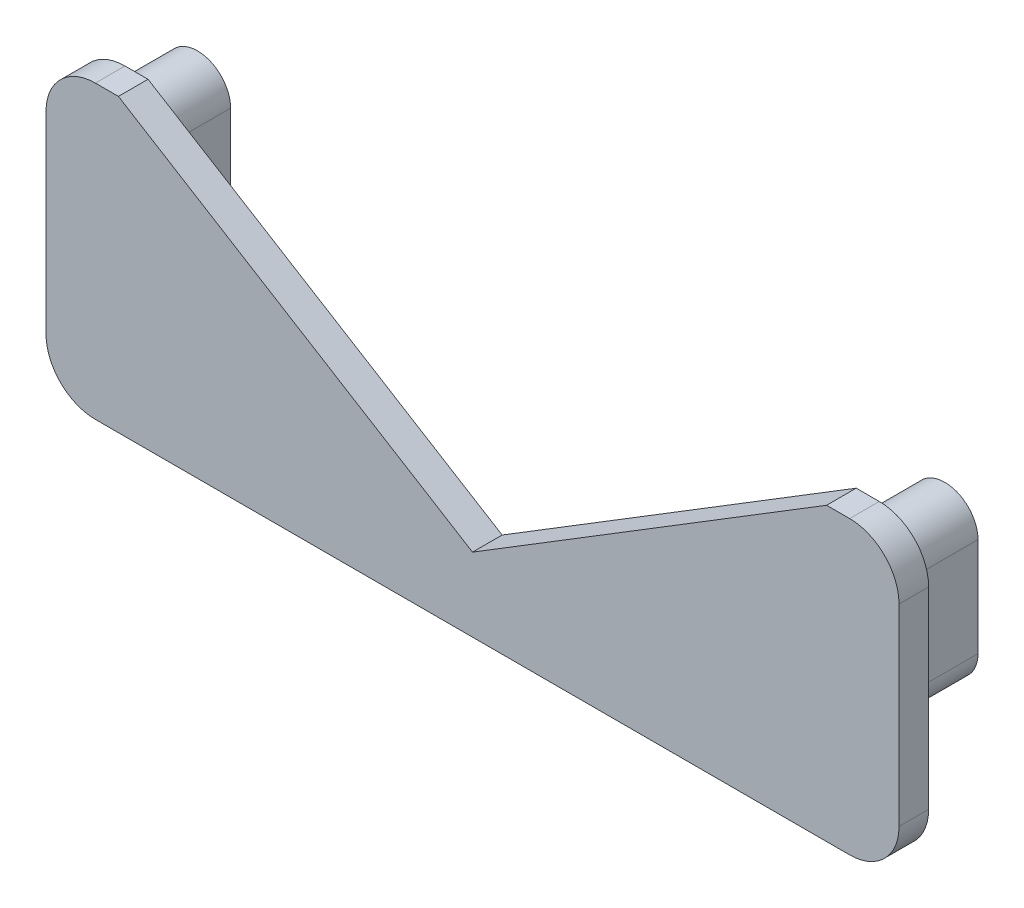
from build123d import *

# Parameters (mm, degrees)
BOSS_EXTRUDE1_DEPTH = 3
BOSS_EXTRUDE2_DEPTH = 7


with BuildPart() as part:
    # Sketch1 → Boss-Extrude1 (new body)
    with BuildSketch(Plane.XY):
        with BuildLine():
            ThreePointArc((-43.2, -9.751954051), (-41.735533906, -13.287487956), (-38.2, -14.751954051))
            Line((-38.2, -14.751954051), (38.2, -14.751954051))
            ThreePointArc((38.2, -14.751954051), (41.735533906, -13.287487956), (43.2, -9.751954051))
            Line((43.2, -9.751954051), (43.2, 9.751954051))
            ThreePointArc((43.2, 9.751954051), (41.735533906, 13.287487956), (38.2, 14.751954051))
            Line((38.2, 14.751954051), (35.865969403, 14.751954051))
            Line((35.865969403, 14.751954051), (0, -7.291716438))
            Line((0, -7.291716438), (-35.865969403, 14.751954051))
            Line((-35.865969403, 14.751954051), (-38.2, 14.751954051))
            ThreePointArc((-38.2, 14.751954051), (-41.735533906, 13.287487956), (-43.2, 9.751954051))
            Line((-43.2, 9.751954051), (-43.2, -9.751954051))
        make_face()
    extrude(amount=BOSS_EXTRUDE1_DEPTH)

    # Sketch1_3 → Boss-Extrude2 (add)
    with BuildSketch(Plane.XY):
        with BuildLine():
            Line((-34.5, -0.598045949), (-34.5, 9.401954051))
            ThreePointArc((-34.5, 9.401954051), (-37.85, 12.751954051), (-41.2, 9.401954051))
            Line((-41.2, 9.401954051), (-41.2, -0.598045949))
            ThreePointArc((-41.2, -0.598045949), (-37.85, -3.948045949), (-34.5, -0.598045949))
        make_face()
        with BuildLine():
            Line((41.2, -0.598045949), (41.2, 9.401954051))
            ThreePointArc((41.2, 9.401954051), (37.85, 12.751954051), (34.5, 9.401954051))
            Line((34.5, 9.401954051), (34.5, -0.598045949))
            ThreePointArc((34.5, -0.598045949), (37.85, -3.948045949), (41.2, -0.598045949))
        make_face()
    extrude(amount=-BOSS_EXTRUDE2_DEPTH)


solid = part.part
